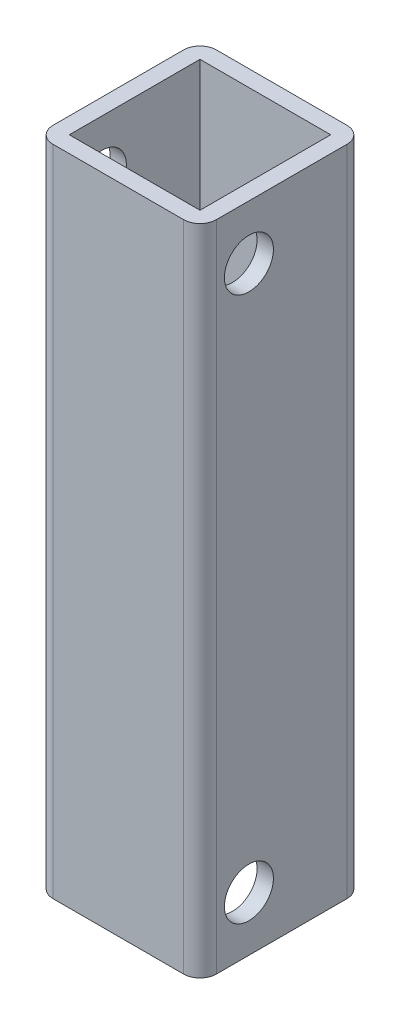
from build123d import *

# Parameters (mm, degrees)
CROQUIS1_W                        = 30
CROQUIS1_H                        = 119.965463257
SALIENTE_EXTRUIR1_DEPTH           = 30
CROQUIS2_W                        = 24
CROQUIS2_H                        = 24
CORTAR_EXTRUIR1_DEPTH             = 120.965463257
DI_METRO_DE_TALADRO_9_0_9_1_D     = 9
DI_METRO_DE_TALADRO_9_0_9_1_DEPTH = 3
DI_METRO_DE_TALADRO_9_0_9_2_D     = 9
DI_METRO_DE_TALADRO_9_0_9_2_DEPTH = 30
REDONDEO1_R                       = 3


with BuildPart() as part:
    # Croquis1 → Saliente-Extruir1 (new body)
    with BuildSketch(Plane.XY.offset(-20.120137415)):
        with Locations((0, 447.917268372)):
            Rectangle(CROQUIS1_W, CROQUIS1_H)
    extrude(amount=-SALIENTE_EXTRUIR1_DEPTH)

    # Croquis2 → Cortar-Extruir1 (cut, through all)
    with BuildSketch(Plane(origin=(0, 507.9, 0), x_dir=(-1, 0, 0), z_dir=(0, 1, 0))):
        with Locations((0, -35.120137415)):
            Rectangle(CROQUIS2_W, CROQUIS2_H)
    extrude(amount=-CORTAR_EXTRUIR1_DEPTH, mode=Mode.SUBTRACT)

    # Diámetro de taladro Ø9.0 (9)1
    with Locations(Plane(origin=(-12, 0, 0), x_dir=(0, 0, -1), z_dir=(1, 0, 0))):
        with Locations((29.1, 397.9345), (29.1, 497.9345)):
            Hole(DI_METRO_DE_TALADRO_9_0_9_1_D / 2, depth=DI_METRO_DE_TALADRO_9_0_9_1_DEPTH)

    # Diámetro de taladro Ø9.0 (9)2
    with Locations(Plane(origin=(15, 0, 0), x_dir=(0, 0, -1), z_dir=(1, 0, 0))):
        with Locations((29.1, 497.9345), (29.1, 397.9345)):
            Hole(DI_METRO_DE_TALADRO_9_0_9_2_D / 2, depth=DI_METRO_DE_TALADRO_9_0_9_2_DEPTH)

    # Redondeo1
    redondeo1_edges = [part.edges().sort_by_distance(p)[0] for p in [
        (15, 447.917268372, -50.120137415),
        (-15, 447.917268372, -50.120137415),
        (15, 447.917268372, -20.120137415),
        (-15, 447.917268372, -20.120137415),
    ]]
    fillet(redondeo1_edges, radius=REDONDEO1_R)


solid = part.part
